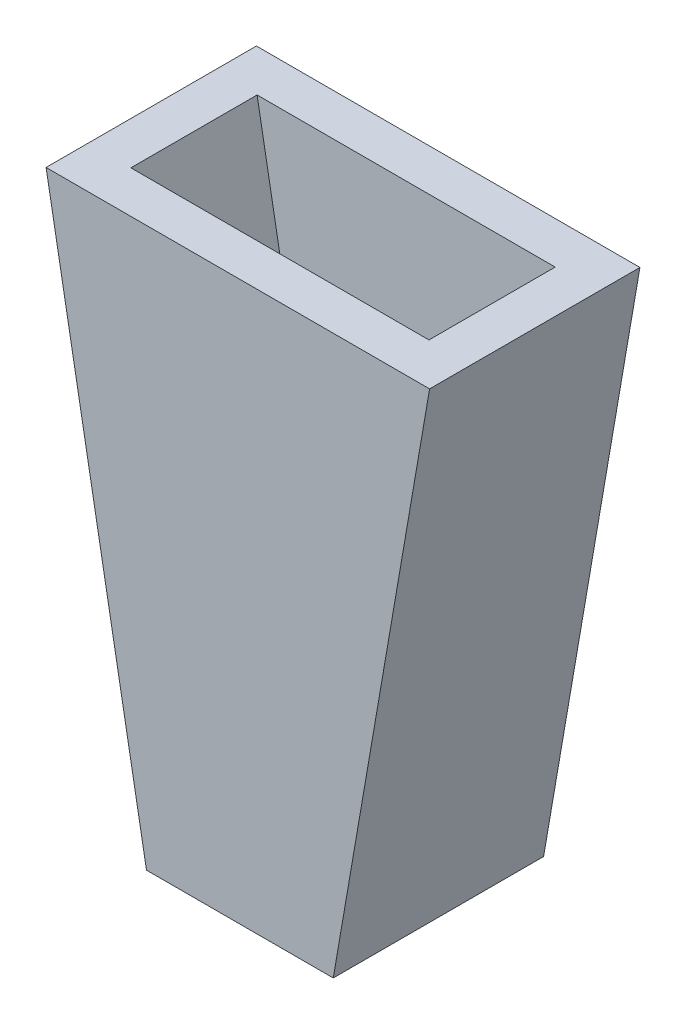
from build123d import *

# Parameters (mm, degrees)
EXTRUDE_1_DEPTH = 7.5
SHELL_1_T       = -1.5


with BuildPart() as part:
    # 草图1 → 凸台-拉伸1 (new body)
    with BuildSketch(Plane.XY):
        Polygon((-22.163477656, 55), (-15.358999723, 55), (-8.487673684, 55), (-11.922964888, 35.089989422), (-18.582368801, 35.089989422), align=None)
    extrude(amount=EXTRUDE_1_DEPTH)

    # 抽壳1
    shell_1_openings = [part.faces().sort_by_distance(p)[0] for p in [
        (-15.32557567, 55, 3.75),
    ]]
    offset(amount=SHELL_1_T, openings=shell_1_openings, kind=Kind.INTERSECTION)


solid = part.part
